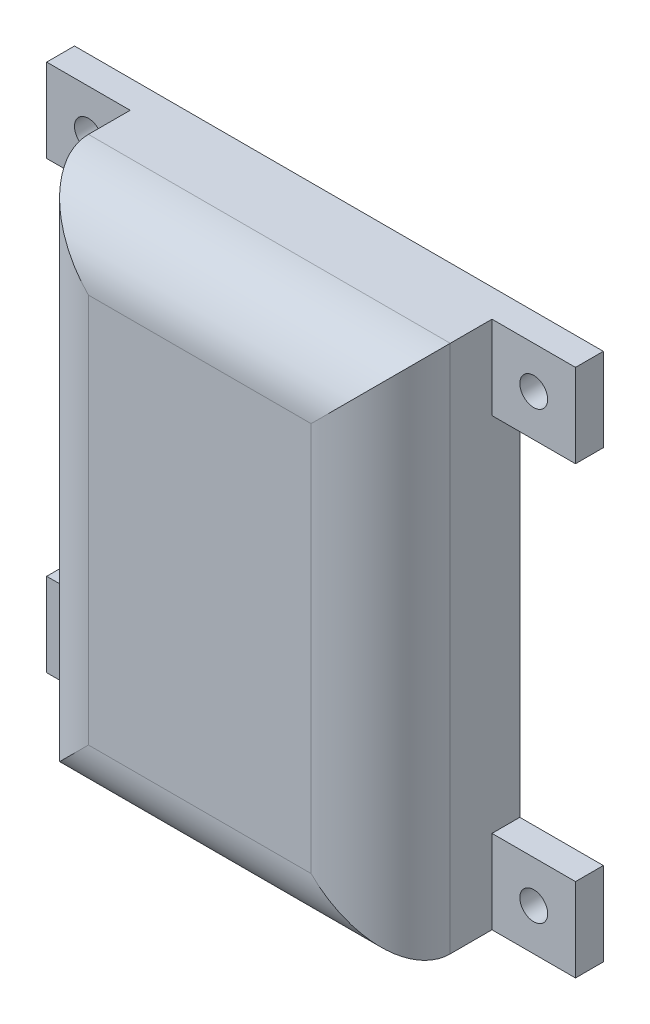
from build123d import *

# Parameters (mm, degrees)
SKETCH_1_W          = 26
SKETCH_1_H          = 38
EXTRUDE_1_DEPTH     = 10
SKETCH_2_W          = 22
SKETCH_2_H          = 34
CUT_EXTRUDE_1_DEPTH = 8
SKETCH_4_W          = 6
SKETCH_4_H          = 6
EXTRUDE_2_DEPTH     = 2
SKETCH_5_R          = 1
CUT_EXTRUDE_4_DEPTH = 2
FILLET_1_R          = 5


with BuildPart() as part:
    # ｽｹｯﾁ1 → ﾎﾞｽ - 押し出し1 (new body)
    with BuildSketch(Plane.XY):
        Rectangle(SKETCH_1_W, SKETCH_1_H)
    extrude(amount=EXTRUDE_1_DEPTH)

    # ｽｹｯﾁ2 → ｶｯﾄ - 押し出し1 (cut)
    with BuildSketch(Plane.XY):
        Rectangle(SKETCH_2_W, SKETCH_2_H)
    extrude(amount=CUT_EXTRUDE_1_DEPTH, mode=Mode.SUBTRACT)

    # ｽｹｯﾁ4 → ﾎﾞｽ - 押し出し2 (add)
    with BuildSketch(Plane.XY):
        with Locations((16, 16)):
            Rectangle(SKETCH_4_W, SKETCH_4_H)
        with Locations((16, -16)):
            Rectangle(SKETCH_4_W, SKETCH_4_H)
        with Locations((-16, -16)):
            Rectangle(SKETCH_4_W, SKETCH_4_H)
        with Locations((-16, 16)):
            Rectangle(SKETCH_4_W, SKETCH_4_H)
    extrude(amount=EXTRUDE_2_DEPTH)

    # ｽｹｯﾁ5 → ｶｯﾄ - 押し出し4 (cut)
    with BuildSketch(Plane.XY):
        with Locations((-16, 16)):
            Circle(SKETCH_5_R)
        with Locations((-16, -16)):
            Circle(SKETCH_5_R)
        with Locations((16, -16)):
            Circle(SKETCH_5_R)
        with Locations((16, 16)):
            Circle(SKETCH_5_R)
    extrude(amount=CUT_EXTRUDE_4_DEPTH, mode=Mode.SUBTRACT)

    # ﾌｨﾚｯﾄ1
    fillet_1_edges = [part.edges().sort_by_distance(p)[0] for p in [
        (0, 19, 10),
        (0, -19, 10),
        (13, 0, 10),
        (-13, 0, 10),
    ]]
    fillet(fillet_1_edges, radius=FILLET_1_R)


solid = part.part
